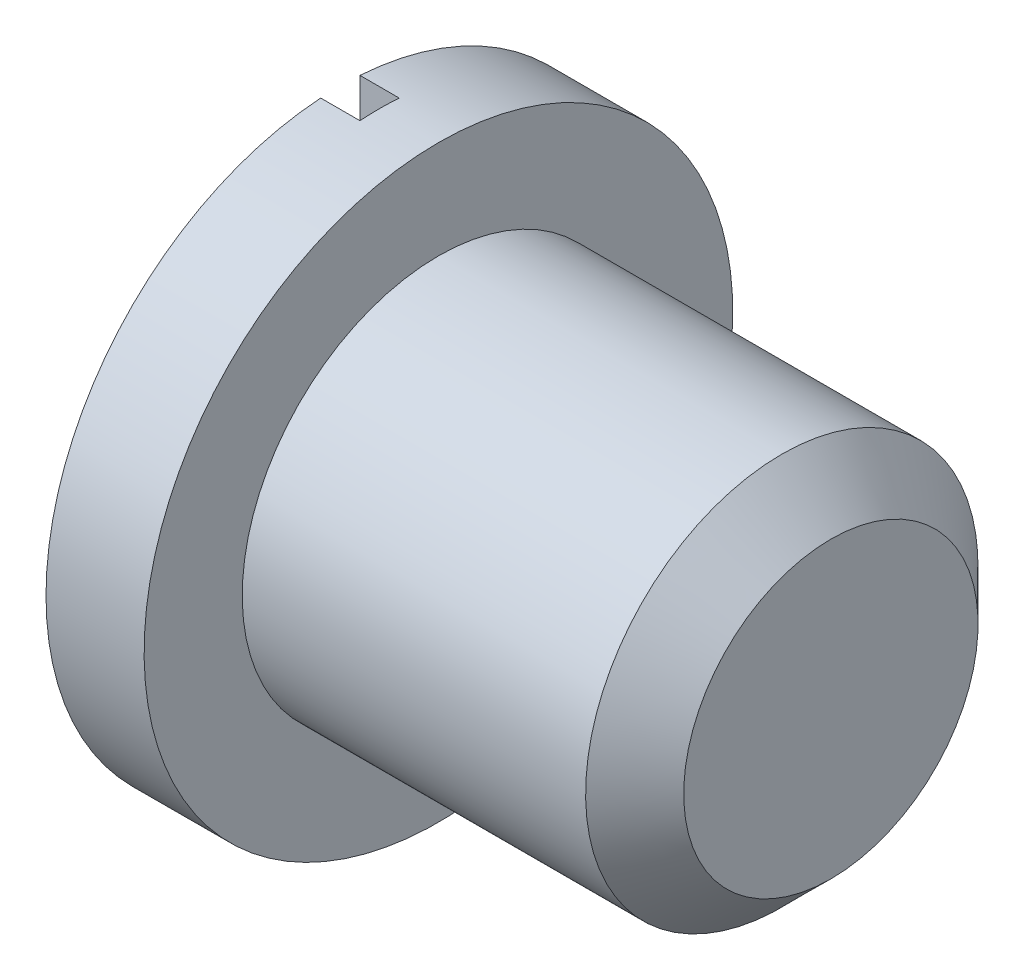
from build123d import *

# Parameters (mm, degrees)
CHAFL_N1_SIZE         = 0.125
CORTAR_EXTRUIR6_DEPTH = 0.1


with BuildPart() as part:
    # Croquis1 → Revolución1 (revolve)
    with BuildSketch(Plane.XY):
        Polygon((0, 0), (0, 0.75), (0.25, 0.75), (0.25, 0.5), (1.25, 0.5), (1.25, 0), align=None)
    revolve(axis=Axis((1.25, 0, 0), (-1, 0, 0)))

    # Chaflán1
    chafl_n1_edges = [part.edges().sort_by_distance(p)[0] for p in [
        (1.25, -0.5, 0),
    ]]
    chamfer(chafl_n1_edges, length=CHAFL_N1_SIZE)

    # Croquis5 → Cortar-Extruir6 (cut)
    with BuildSketch(Plane.ZY):
        with BuildLine():
            Line((-0.05, 0.748331477), (-0.05, -0.748331477))
            ThreePointArc((-0.05, -0.748331477), (0, -0.75), (0.05, -0.748331477))
            Line((0.05, -0.748331477), (0.05, 0.748331477))
            ThreePointArc((0.05, 0.748331477), (0, 0.75), (-0.05, 0.748331477))
        make_face()
    extrude(amount=-CORTAR_EXTRUIR6_DEPTH, mode=Mode.SUBTRACT)


solid = part.part
